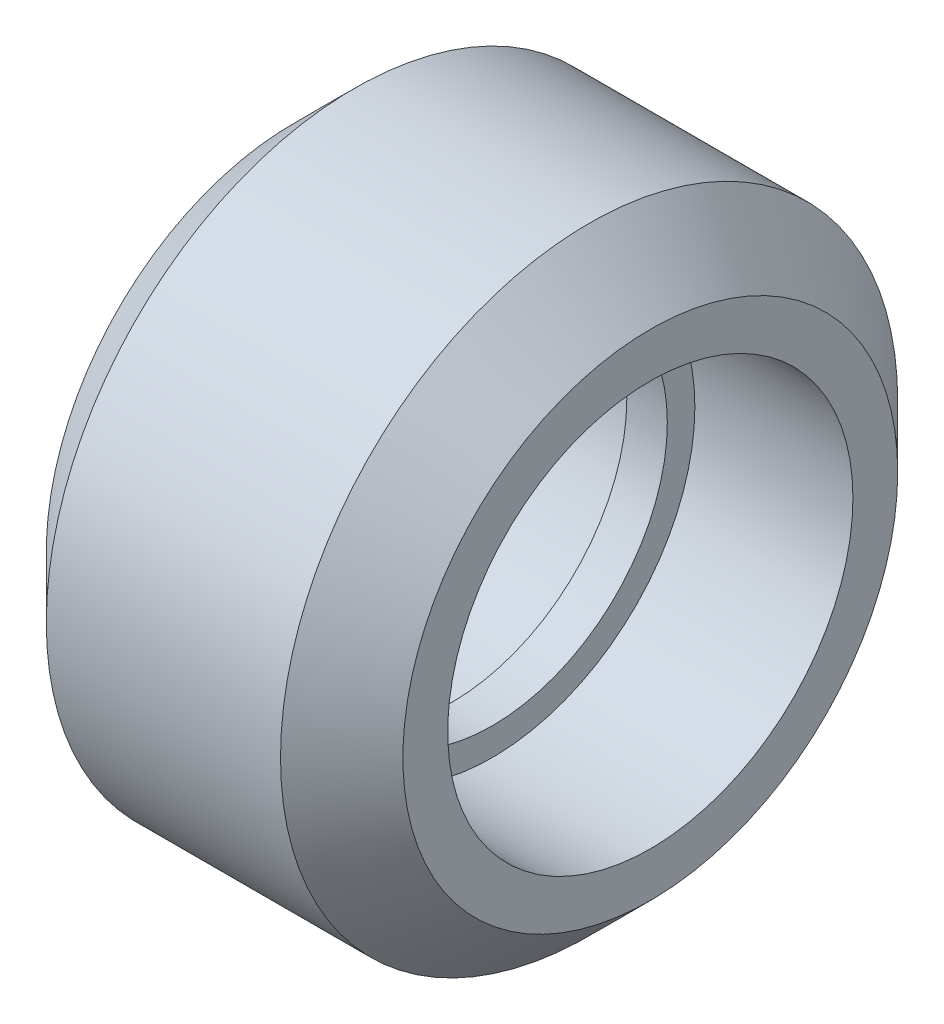
from build123d import *


with BuildPart() as part:
    # Sketch1 → Revolve1 (revolve)
    with BuildSketch(Plane.XY):
        Polygon((0.5, 4.32), (-0.5, 4.32), (-0.5, 5), (-4.4, 5), (-4.4, 6.105), (-2.89, 7.615), (2.89, 7.615), (4.4, 6.105), (4.4, 5), (0.5, 5), align=None)
    revolve(axis=Axis((0, 0, 0), (-1, 0, 0)))


solid = part.part
